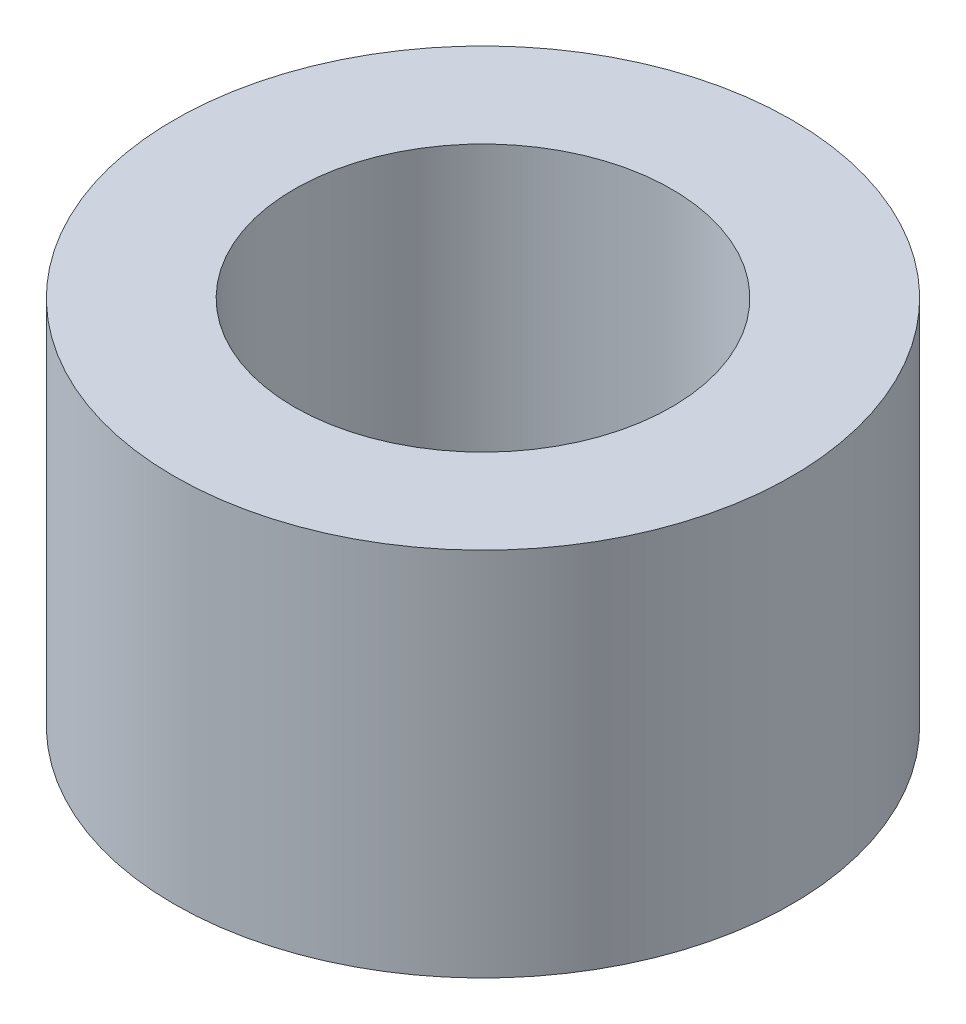
from build123d import *

# Parameters (mm, degrees)
SKETCH1_R           = 7.9375
SKETCH1_R_2         = 4.8514
BOSS_EXTRUDE1_DEPTH = 9.525


with BuildPart() as part:
    # Sketch1 → Boss-Extrude1 (new body)
    with BuildSketch(Plane(origin=(0, 0, 0), x_dir=(1, 0, 0), z_dir=(0, 1, 0))):
        Circle(SKETCH1_R)
        Circle(SKETCH1_R_2, mode=Mode.SUBTRACT)
    extrude(amount=BOSS_EXTRUDE1_DEPTH)


solid = part.part
